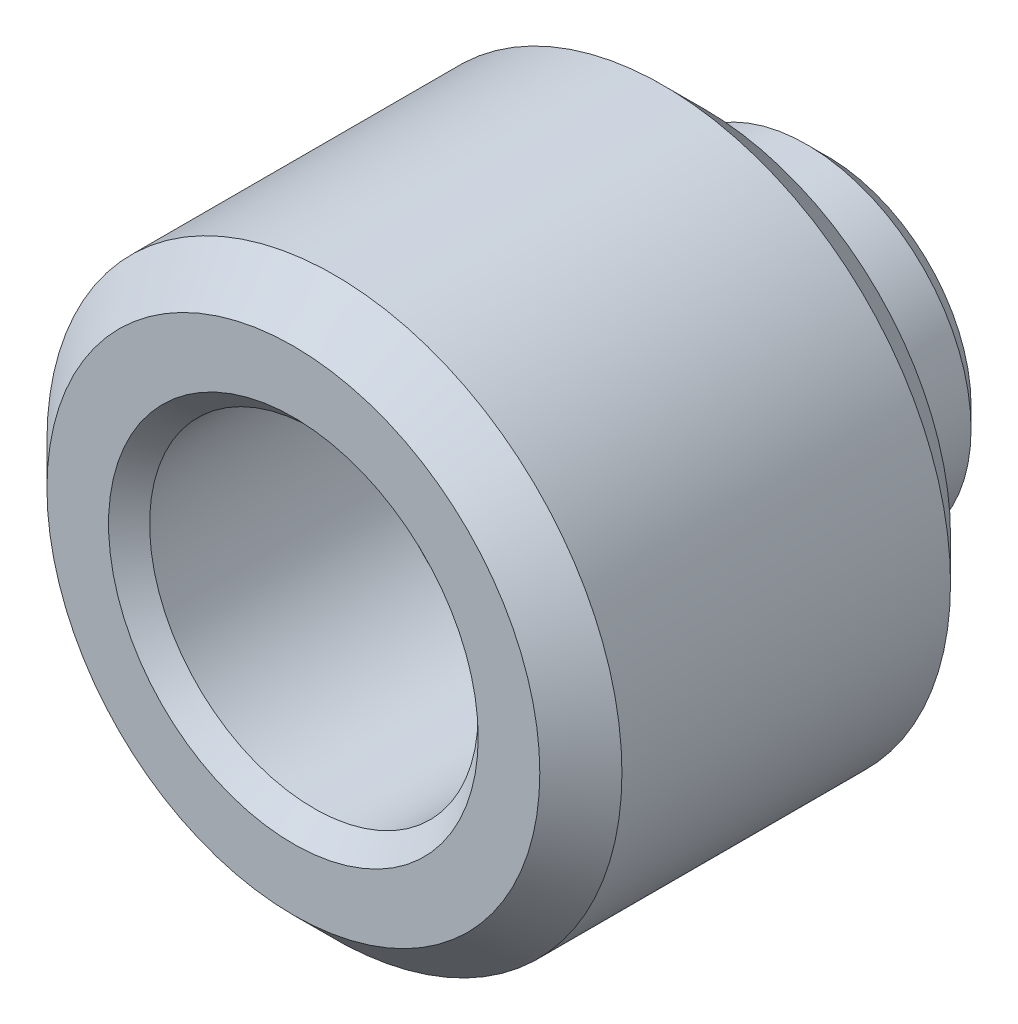
from build123d import *

# Parameters (mm, degrees)
SKETCH_1_R      = 7
SKETCH_1_R_2    = 4
EXTRUDE_1_DEPTH = 10
SKETCH_2_R      = 4
SKETCH_2_R_2    = 2.2
EXTRUDE_2_DEPTH = 7
CHAMFER_1_SIZE  = 1
CHAMFER_2_SIZE  = 0.5
CHAMFER_3_SIZE  = 0.5


with BuildPart() as part:
    # 草图1 → 凸台-拉伸1 (new body)
    with BuildSketch(Plane.XY):
        with Locations((42.877900702, -281.152618372)):
            Circle(SKETCH_1_R)
        with Locations((42.877900702, -281.152618372)):
            Circle(SKETCH_1_R_2, mode=Mode.SUBTRACT)
    extrude(amount=EXTRUDE_1_DEPTH)

    # 草图2 → 凸台-拉伸2 (add)
    with BuildSketch(Plane.XY.offset(-3)):
        with Locations((42.877900702, -281.152618372)):
            Circle(SKETCH_2_R)
        with Locations((42.877900702, -281.152618372)):
            Circle(SKETCH_2_R_2, mode=Mode.SUBTRACT)
    extrude(amount=EXTRUDE_2_DEPTH)

    # 倒角1
    chamfer_1_edges = [part.edges().sort_by_distance(p)[0] for p in [
        (35.877900702, -281.152618372, 0),
        (35.877900702, -281.152618372, 10),
    ]]
    chamfer(chamfer_1_edges, length=CHAMFER_1_SIZE)

    # 倒角2
    chamfer_2_edges = [part.edges().sort_by_distance(p)[0] for p in [
        (38.877900702, -281.152618372, -3),
    ]]
    chamfer(chamfer_2_edges, length=CHAMFER_2_SIZE)

    # 倒角3
    chamfer_3_edges = [part.edges().sort_by_distance(p)[0] for p in [
        (38.877900702, -281.152618372, 10),
    ]]
    chamfer(chamfer_3_edges, length=CHAMFER_3_SIZE)


solid = part.part
